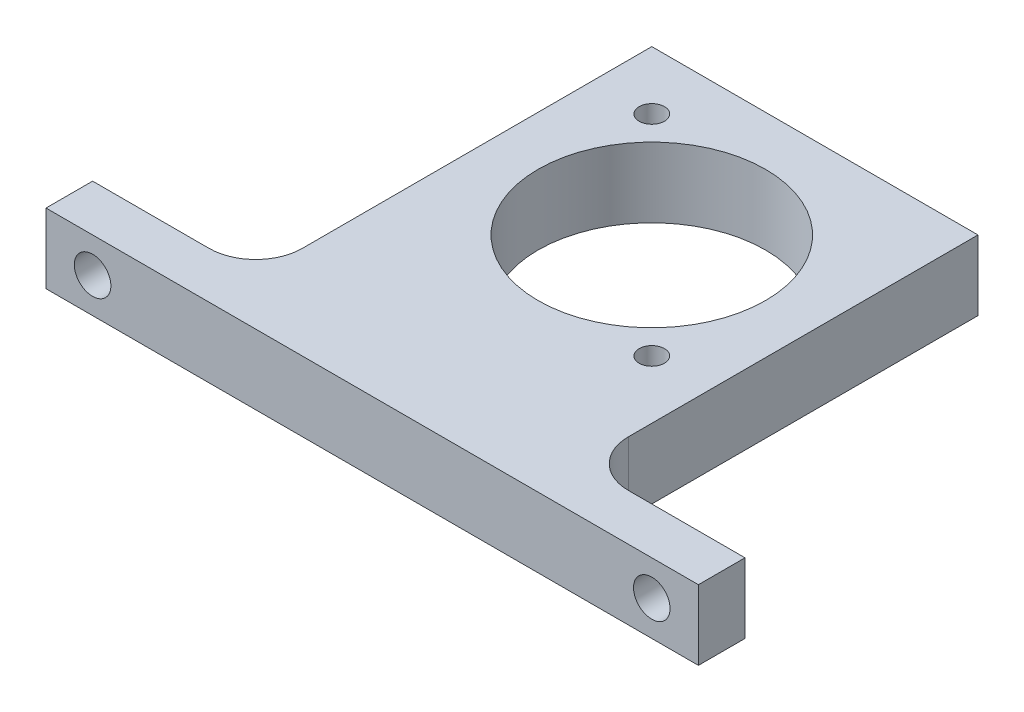
from build123d import *

# Parameters (mm, degrees)
SKETCH1_W             = 44.45
SKETCH1_H             = 60.325
BOSS_EXTRUDE1_DEPTH   = 9.525
SKETCH7_W             = 22.225
SKETCH7_H             = 9.525
BOSS_EXTRUDE3_DEPTH   = 6.35
FILLET1_R             = 6.35
SKETCH8_R             = 2.4892
CUT_EXTRUDE1_DEPTH    = 6.35
CUT_EXTRUDE2_REACH    = 11.525
SKETCH10_R            = 15.494
SKETCH10_R_2          = 1.7272
F_8_32_TAPPED_HOLE2_D = 3.4544


with BuildPart() as part:
    # Sketch1 → Boss-Extrude1 (new body)
    with BuildSketch(Plane(origin=(0, 0, 0), x_dir=(1, 0, 0), z_dir=(0, 1, 0))):
        with Locations((0, -7.9375)):
            Rectangle(SKETCH1_W, SKETCH1_H)
    extrude(amount=BOSS_EXTRUDE1_DEPTH)

    # Sketch7 → Boss-Extrude3 (add)
    with BuildSketch(Plane.XY.offset(38.1)):
        with Locations((-33.3375, 4.7625)):
            Rectangle(SKETCH7_W, SKETCH7_H)
        with Locations((33.3375, 4.7625)):
            Rectangle(SKETCH7_W, SKETCH7_H)
    extrude(amount=-BOSS_EXTRUDE3_DEPTH)

    # Fillet1
    fillet1_edges = [part.edges().sort_by_distance(p)[0] for p in [
        (-22.225, 4.7625, 31.75),
        (22.225, 4.7625, 31.75),
    ]]
    fillet(fillet1_edges, radius=FILLET1_R)

    # Sketch8 → Cut-Extrude1 (cut)
    with BuildSketch(Plane.XY.offset(38.1)):
        with Locations((-38.1, 4.7625)):
            Circle(SKETCH8_R)
        with Locations((38.1, 4.7625)):
            Circle(SKETCH8_R)
    extrude(amount=-CUT_EXTRUDE1_DEPTH, mode=Mode.SUBTRACT)

    # Sketch10 → Cut-Extrude2 (cut, up to next)
    with BuildSketch(Plane(origin=(0, 9.525, 0), x_dir=(1, 0, 0), z_dir=(0, 1, 0)), mode=Mode.PRIVATE) as cut_extrude2_sk1:
        Circle(SKETCH10_R)
    cut_extrude2_tool1 = extrude(cut_extrude2_sk1.sketch, amount=-CUT_EXTRUDE2_REACH, mode=Mode.PRIVATE) & part.part
    add(cut_extrude2_tool1.solids().sort_by_distance((0, 9.525, 0))[0], mode=Mode.SUBTRACT)
    # Sketch10 → Cut-Extrude2 (cut, up to next)
    with BuildSketch(Plane(origin=(0, 9.525, 0), x_dir=(1, 0, 0), z_dir=(0, 1, 0)), mode=Mode.PRIVATE) as cut_extrude2_sk2:
        with Locations((-14.278607233, 14.278607232)):
            Circle(SKETCH10_R_2)
    cut_extrude2_tool2 = extrude(cut_extrude2_sk2.sketch, amount=-CUT_EXTRUDE2_REACH, mode=Mode.PRIVATE) & part.part
    add(cut_extrude2_tool2.solids().sort_by_distance((-14.278607, 9.525, -14.278607))[0], mode=Mode.SUBTRACT)
    # Sketch10 → Cut-Extrude2 (cut, up to next)
    with BuildSketch(Plane(origin=(0, 9.525, 0), x_dir=(1, 0, 0), z_dir=(0, 1, 0)), mode=Mode.PRIVATE) as cut_extrude2_sk3:
        with Locations((14.278607232, -14.278607232)):
            Circle(SKETCH10_R_2)
    cut_extrude2_tool3 = extrude(cut_extrude2_sk3.sketch, amount=-CUT_EXTRUDE2_REACH, mode=Mode.PRIVATE) & part.part
    add(cut_extrude2_tool3.solids().sort_by_distance((14.278607, 9.525, 14.278607))[0], mode=Mode.SUBTRACT)

    # #8-32 Tapped Hole2 (through all)
    with Locations(Plane(origin=(0, 9.525, 0), x_dir=(1, 0, 0), z_dir=(0, 1, 0))):
        with Locations((-14.278607233, 14.278607232), (14.278607232, -14.278607232)):
            Hole(F_8_32_TAPPED_HOLE2_D / 2)


solid = part.part
